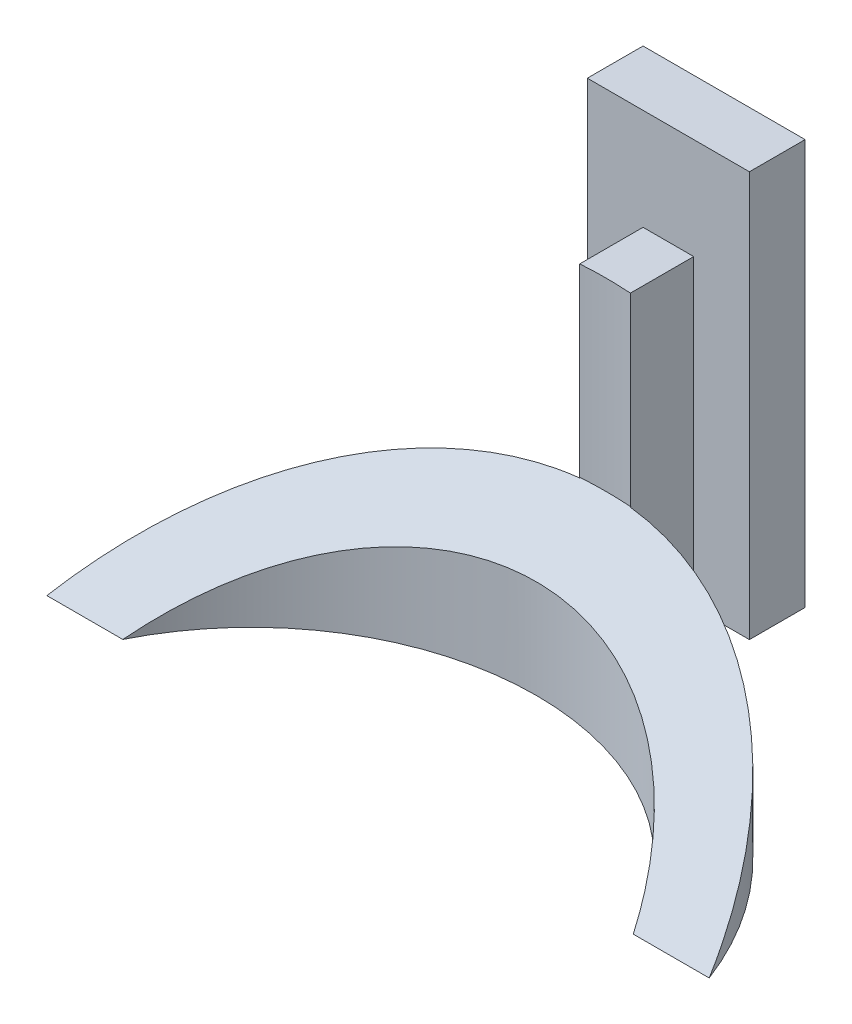
from build123d import *

# Parameters (mm, degrees)
SKETCH1_W               = 16
SKETCH1_H               = 5
BOSS_EXTRUDE1_DEPTH     = 30
BOSS_EXTRUDE2_START     = -2.25
BOSS_EXTRUDE2_DEPTH     = 14
CUT_EXTRUDE1_DEPTH      = 33.691742077
CUT_EXTRUDE1_DEPTH_BACK = 33.691742077
BOSS_EXTRUDE3_START     = 30
SKETCH1_3_W             = 16
SKETCH1_3_H             = 5
BOSS_EXTRUDE3_DEPTH     = 10
SKETCH5_W               = 16
SKETCH5_H               = 0.5
BOSS_EXTRUDE4_DEPTH     = 40


with BuildPart() as part:
    # Sketch1 → Boss-Extrude1 (new body)
    with BuildSketch(Plane(origin=(0, 0, 0), x_dir=(1, 0, 0), z_dir=(0, 1, 0))):
        Rectangle(SKETCH1_W, SKETCH1_H)
        with BuildLine():
            Line((2.5, -9.25), (2.5, -2.5))
            Line((2.5, -2.5), (-2.5, -2.5))
            Line((-2.5, -2.5), (-2.5, -9.25))
            ThreePointArc((-2.5, -9.25), (0, -9.160600109), (2.5, -9.25))
        make_face()
    extrude(amount=BOSS_EXTRUDE1_DEPTH)

    # Sketch2 → Boss-Extrude2 (add)
    with BuildSketch(Plane(origin=(0, 0, 0), x_dir=(1, 0, 0), z_dir=(0, 1, 0)).offset(BOSS_EXTRUDE2_START)):
        with BuildLine():
            ThreePointArc((32.691742077, -31.660600109), (0, -9.160600109), (-32.691742077, -31.660600109))
            Line((-32.691742077, -31.660600109), (-25.194555463, -31.660600109))
            ThreePointArc((-25.194555463, -31.660600109), (0, -16.035600109), (25.194555463, -31.660600109))
            Line((25.194555463, -31.660600109), (32.691742077, -31.660600109))
        make_face()
    extrude(amount=BOSS_EXTRUDE2_DEPTH)

    # Sketch3 → Cut-Extrude1 (cut, two sides)
    with BuildSketch(Plane(origin=(0, 0, 0), x_dir=(0, 0, -1), z_dir=(1, 0, 0))) as cut_extrude1_sk:
        Polygon((-31.660600109, -2.25), (-31.660600109, 11.75), (-9.160600109, 11.75), align=None)
    extrude(amount=CUT_EXTRUDE1_DEPTH, mode=Mode.SUBTRACT)
    extrude(cut_extrude1_sk.sketch, amount=-CUT_EXTRUDE1_DEPTH_BACK, mode=Mode.SUBTRACT)

    # Sketch1_3 → Boss-Extrude3 (add)
    with BuildSketch(Plane(origin=(0, 0, 0), x_dir=(1, 0, 0), z_dir=(0, 1, 0)).offset(BOSS_EXTRUDE3_START)):
        Rectangle(SKETCH1_3_W, SKETCH1_3_H)
    extrude(amount=BOSS_EXTRUDE3_DEPTH)

    # Sketch5 → Boss-Extrude4 (add)
    with BuildSketch(Plane(origin=(0, 40, 0), x_dir=(1, 0, 0), z_dir=(0, 1, 0))):
        with Locations((0, -2.75)):
            Rectangle(SKETCH5_W, SKETCH5_H)
    extrude(amount=-BOSS_EXTRUDE4_DEPTH)


solid = part.part
